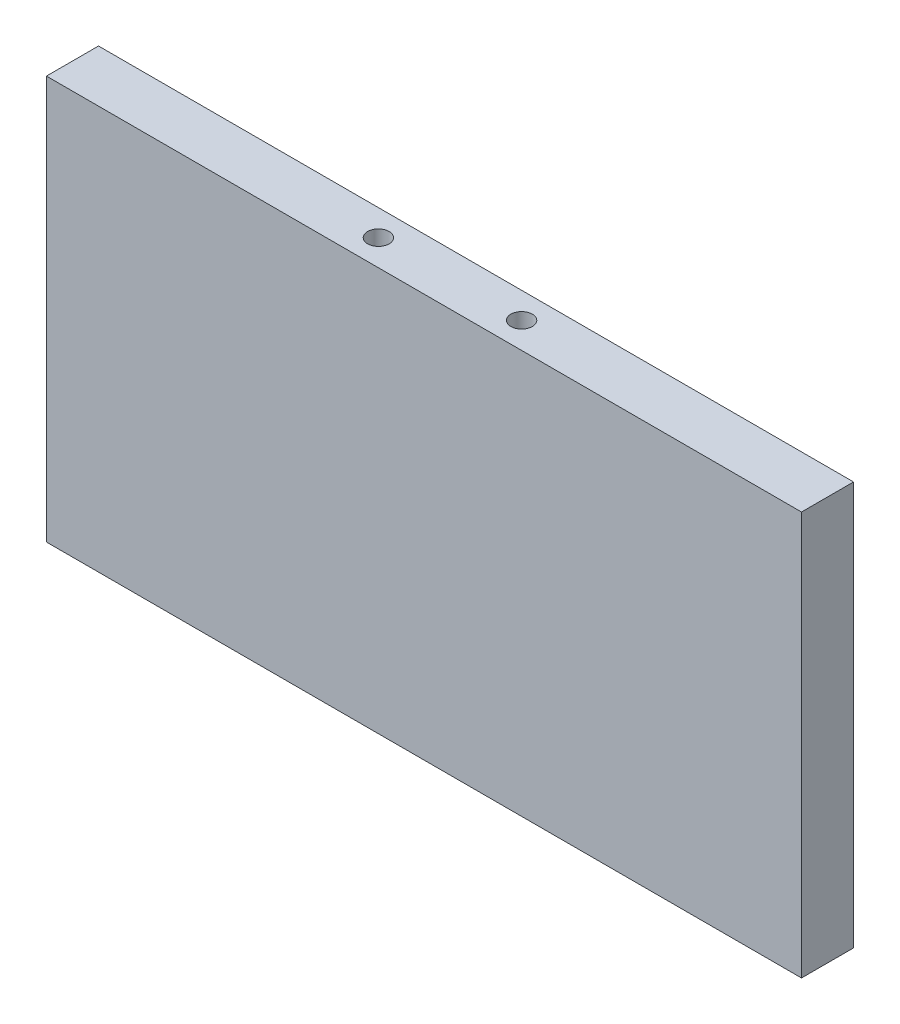
from build123d import *

# Parameters (mm, degrees)
ESQUISSE1_W             = 116
ESQUISSE1_H             = 62
BOSS_EXTRU_1_DEPTH      = 8
ESQUISSE2_R             = 1.65
ENL_V_MAT_EXTRU_1_DEPTH = 10


with BuildPart() as part:
    # Esquisse1 → Boss.-Extru.1 (new body)
    with BuildSketch(Plane.XY):
        with Locations((58, 31)):
            Rectangle(ESQUISSE1_W, ESQUISSE1_H)
    extrude(amount=BOSS_EXTRU_1_DEPTH)

    # Esquisse2 → Enlèv. mat.-Extru.1 (cut)
    with BuildSketch(Plane(origin=(0, 62, 0), x_dir=(1, 0, 0), z_dir=(0, 1, 0))):
        with Locations((47, -4)):
            Circle(ESQUISSE2_R)
        with Locations((69, -4)):
            Circle(ESQUISSE2_R)
    extrude(amount=-ENL_V_MAT_EXTRU_1_DEPTH, mode=Mode.SUBTRACT)


solid = part.part
